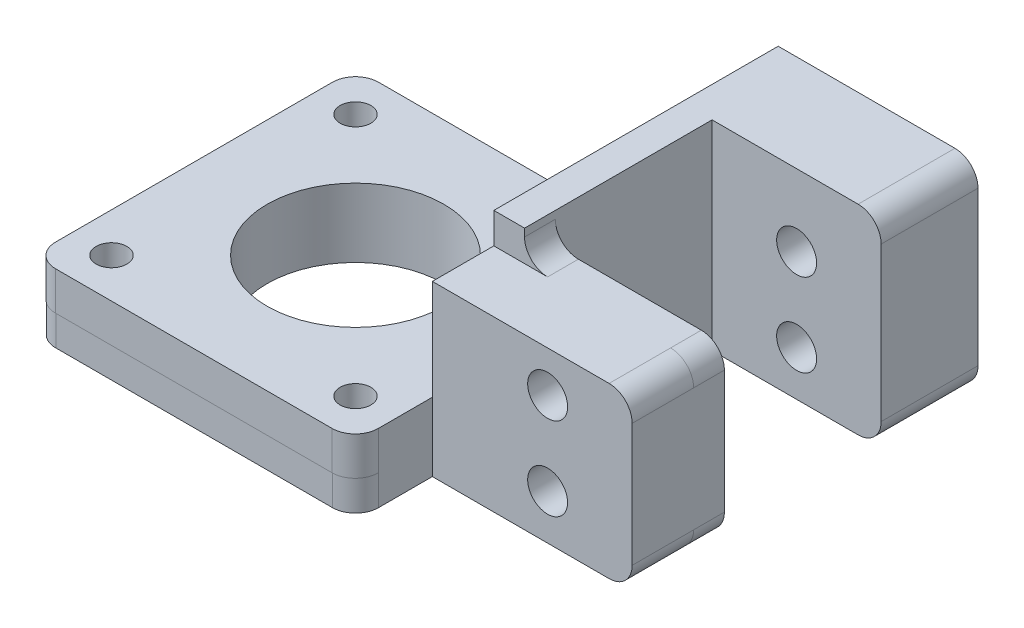
from build123d import *

# Parameters (mm, degrees)
SKETCH1_W            = 22
SKETCH1_H            = 22
BOSS_EXTRUDE2_DEPTH  = 4
SKETCH3_W            = 4
SKETCH3_H            = 22
BOSS_EXTRUDE3_DEPTH  = 24
SKETCH4_W            = 4
SKETCH4_H            = 24
BOSS_EXTRUDE4_DEPTH  = 4
SKETCH5_W            = 24
SKETCH5_H            = 4
BOSS_EXTRUDE5_DEPTH  = 24
SKETCH6_W            = 42
SKETCH6_H            = 3.943894778
BOSS_EXTRUDE6_DEPTH  = 42
SKETCH8_W            = 42
SKETCH8_H            = 42
BOSS_EXTRUDE7_DEPTH  = 4
SKETCH9_R            = 11.5
CUT_EXTRUDE1_DEPTH   = 4
SKETCH10_R           = 2.6
CUT_EXTRUDE2_DEPTH   = 4
SKETCH11_R           = 2.6
CUT_EXTRUDE3_DEPTH   = 4
FILLET1_R            = 3
SKETCH12_W           = 11.614383954
SKETCH12_H           = 9.896110461
BOSS_EXTRUDE8_DEPTH  = 4
SKETCH13_R           = 2.6
CUT_EXTRUDE5_DEPTH   = 4
SKETCH15_R           = 2
CUT_EXTRUDE7_DEPTH   = 27
SKETCH16_W           = 42
SKETCH16_H           = 42
CUT_EXTRUDE8_DEPTH   = 10
SKETCH17_W           = 42
SKETCH17_H           = 42.03828493
BOSS_EXTRUDE9_DEPTH  = 5
FILLET2_R            = 3
FILLET3_R            = 3
SKETCH18_R           = 2
SKETCH18_R_2         = 11.5
CUT_EXTRUDE9_DEPTH   = 5
SKETCH19_W           = 26
SKETCH19_H           = 22
BOSS_EXTRUDE11_DEPTH = 8
FILLET4_R            = 3
FILLET5_R            = 3
SKETCH20_W           = 4
SKETCH20_H           = 20
BOSS_EXTRUDE12_DEPTH = 26
SKETCH21_W           = 4
SKETCH21_H           = 26
BOSS_EXTRUDE13_DEPTH = 13
SKETCH25_W           = 12.6
SKETCH25_H           = 26
BOSS_EXTRUDE15_DEPTH = 22
FILLET8_R            = 3
FILLET9_R            = 3
SKETCH27_R           = 2.6
CUT_EXTRUDE10_DEPTH  = 22
SKETCH28_R           = 2.6
CUT_EXTRUDE11_DEPTH  = 46.0000001


with BuildPart() as part:
    # Sketch1 → Boss-Extrude2 (new body)
    with BuildSketch(Plane.XY):
        Rectangle(SKETCH1_W, SKETCH1_H)
    extrude(amount=BOSS_EXTRUDE2_DEPTH)

    # Sketch3 → Boss-Extrude3 (add)
    with BuildSketch(Plane.XY.offset(4)):
        with Locations((-13, 0)):
            Rectangle(SKETCH3_W, SKETCH3_H)
    extrude(amount=-BOSS_EXTRUDE3_DEPTH)

    # Sketch4 → Boss-Extrude4 (add)
    with BuildSketch(Plane(origin=(0, 11, 0), x_dir=(1, 0, 0), z_dir=(0, 1, 0))):
        with Locations((-13, 8)):
            Rectangle(SKETCH4_W, SKETCH4_H)
    extrude(amount=BOSS_EXTRUDE4_DEPTH)

    # Sketch5 → Boss-Extrude5 (add)
    with BuildSketch(Plane(origin=(-11, 0, 0), x_dir=(0, 0, -1), z_dir=(1, 0, 0))):
        with Locations((8, 13)):
            Rectangle(SKETCH5_W, SKETCH5_H)
    extrude(amount=-BOSS_EXTRUDE5_DEPTH)

    # Sketch6 → Boss-Extrude6 (add)
    with BuildSketch(Plane.ZY.offset(15)):
        with Locations((1, -9.028052611)):
            Rectangle(SKETCH6_W, SKETCH6_H)
    extrude(amount=BOSS_EXTRUDE6_DEPTH)

    # Sketch8 → Boss-Extrude7 (add)
    with BuildSketch(Plane(origin=(0, 15, 0), x_dir=(1, 0, 0), z_dir=(0, 1, 0))):
        with Locations((-36, -1)):
            Rectangle(SKETCH8_W, SKETCH8_H)
    extrude(amount=-BOSS_EXTRUDE7_DEPTH)

    # Sketch9 → Cut-Extrude1 (cut)
    with BuildSketch(Plane.XZ.offset(11)):
        with Locations((-36, 1)):
            Circle(SKETCH9_R)
    extrude(amount=-CUT_EXTRUDE1_DEPTH, mode=Mode.SUBTRACT)

    # Sketch10 → Cut-Extrude2 (cut)
    with BuildSketch(Plane(origin=(0, 15, 0), x_dir=(1, 0, 0), z_dir=(0, 1, 0))):
        with Locations((-34, -1)):
            Circle(SKETCH10_R)
    extrude(amount=-CUT_EXTRUDE2_DEPTH, mode=Mode.SUBTRACT)

    # Sketch11 → Cut-Extrude3 (cut)
    with BuildSketch(Plane.XY.offset(4)):
        with Locations((0, 5.660439733)):
            Circle(SKETCH11_R)
        with Locations((0, -5.136008772)):
            Circle(SKETCH11_R)
    extrude(amount=-CUT_EXTRUDE3_DEPTH, mode=Mode.SUBTRACT)

    # Fillet1
    fillet1_edges = [part.edges().sort_by_distance(p)[0] for p in [
        (-11, 2, -20),
        (-11, 11, 2),
        (-15, -9.028052611, 22),
        (-57, -9.028052611, -20),
        (-57, -9.028052611, 22),
        (11, -11, 2),
        (11, 11, 2),
        (-57, 13, 22),
        (-57, 13, -20),
        (-15, 13, 22),
    ]]
    fillet(fillet1_edges, radius=FILLET1_R)

    # Sketch12 → Boss-Extrude8 (add)
    with BuildSketch(Plane(origin=(0, 15, 0), x_dir=(1, 0, 0), z_dir=(0, 1, 0))):
        with Locations((-34.256477643, -1.105652727)):
            Rectangle(SKETCH12_W, SKETCH12_H)
    extrude(amount=-BOSS_EXTRUDE8_DEPTH)

    # Sketch13 → Cut-Extrude5 (cut)
    with BuildSketch(Plane.XZ.offset(-11)):
        with Locations((-36, 1)):
            Circle(SKETCH13_R)
    extrude(amount=-CUT_EXTRUDE5_DEPTH, mode=Mode.SUBTRACT)

    # Sketch15 → Cut-Extrude7 (cut, through all)
    with BuildSketch(Plane.XZ.offset(11)):
        with Locations((-20.125452762, 16.874547238)):
            Circle(SKETCH15_R)
        with Locations((-51.874547238, 16.874547238)):
            Circle(SKETCH15_R)
        with Locations((-51.874547238, -14.874547238)):
            Circle(SKETCH15_R)
        with Locations((-20.125452762, -14.874547238)):
            Circle(SKETCH15_R)
    extrude(amount=-CUT_EXTRUDE7_DEPTH, mode=Mode.SUBTRACT)

    # Sketch16 → Cut-Extrude8 (cut)
    with BuildSketch(Plane.XZ.offset(-11)):
        with Locations((-36, 1)):
            Rectangle(SKETCH16_W, SKETCH16_H)
    extrude(amount=-CUT_EXTRUDE8_DEPTH, mode=Mode.SUBTRACT)

    # Sketch17 → Boss-Extrude9 (add)
    with BuildSketch(Plane(origin=(0, -7.056105222, 0), x_dir=(1, 0, 0), z_dir=(0, 1, 0))):
        with Locations((-36, -1.019142465)):
            Rectangle(SKETCH17_W, SKETCH17_H)
    extrude(amount=BOSS_EXTRUDE9_DEPTH)

    # Fillet2
    fillet2_edges = [part.edges().sort_by_distance(p)[0] for p in [
        (-15, -4.556105222, 22.03828493),
    ]]
    fillet(fillet2_edges, radius=FILLET2_R)

    # Fillet3
    fillet3_edges = [part.edges().sort_by_distance(p)[0] for p in [
        (-57, -4.556105222, -20),
        (-57, -4.556105222, 22.03828493),
    ]]
    fillet(fillet3_edges, radius=FILLET3_R)

    # Sketch18 → Cut-Extrude9 (cut)
    with BuildSketch(Plane.XZ.offset(7.056105222)):
        with Locations((-20.125452762, 16.874547238)):
            Circle(SKETCH18_R)
        with Locations((-51.874547238, 16.874547238)):
            Circle(SKETCH18_R)
        with Locations((-51.874547238, -14.874547238)):
            Circle(SKETCH18_R)
        with Locations((-20.125452762, -14.874547238)):
            Circle(SKETCH18_R)
        with Locations((-36, 1)):
            Circle(SKETCH18_R_2)
    extrude(amount=-CUT_EXTRUDE9_DEPTH, mode=Mode.SUBTRACT)

    # Sketch19 → Boss-Extrude11 (add)
    with BuildSketch(Plane.XY.offset(4)):
        with Locations((-2, 0)):
            Rectangle(SKETCH19_W, SKETCH19_H)
    extrude(amount=BOSS_EXTRUDE11_DEPTH)

    # Fillet4
    fillet4_edges = [part.edges().sort_by_distance(p)[0] for p in [
        (11, 11, 8),
    ]]
    fillet(fillet4_edges, radius=FILLET4_R)

    # Fillet5
    fillet5_edges = [part.edges().sort_by_distance(p)[0] for p in [
        (11, -11, 8),
    ]]
    fillet(fillet5_edges, radius=FILLET5_R)

    # Sketch20 → Boss-Extrude12 (add, through all)
    with BuildSketch(Plane(origin=(0, 15, 0), x_dir=(1, 0, 0), z_dir=(0, 1, 0))):
        with Locations((-13, 10)):
            Rectangle(SKETCH20_W, SKETCH20_H)
    extrude(amount=-BOSS_EXTRUDE12_DEPTH)

    # Sketch21 → Boss-Extrude13 (add)
    with BuildSketch(Plane(origin=(0, 0, -20), x_dir=(-1, 0, 0), z_dir=(0, 0, -1))):
        with Locations((13, 2)):
            Rectangle(SKETCH21_W, SKETCH21_H)
    extrude(amount=BOSS_EXTRUDE13_DEPTH)

    # Sketch25 → Boss-Extrude15 (add)
    with BuildSketch(Plane(origin=(-11, 0, 0), x_dir=(0, 0, -1), z_dir=(1, 0, 0))):
        with Locations((26.7, 2)):
            Rectangle(SKETCH25_W, SKETCH25_H)
    extrude(amount=BOSS_EXTRUDE15_DEPTH)

    # Fillet8
    fillet8_edges = [part.edges().sort_by_distance(p)[0] for p in [
        (11, 15, -26.7),
    ]]
    fillet(fillet8_edges, radius=FILLET8_R)

    # Fillet9
    fillet9_edges = [part.edges().sort_by_distance(p)[0] for p in [
        (11, -11, -26.7),
    ]]
    fillet(fillet9_edges, radius=FILLET9_R)

    # Sketch27 → Cut-Extrude10 (cut)
    with BuildSketch(Plane(origin=(0, 0, 0), x_dir=(-1, 0, 0), z_dir=(0, 0, -1))):
        with Locations((0, 5.660439733)):
            Circle(SKETCH27_R)
        with Locations((0, -5.136008772)):
            Circle(SKETCH27_R)
    extrude(amount=-CUT_EXTRUDE10_DEPTH, mode=Mode.SUBTRACT)

    # Sketch28 → Cut-Extrude11 (cut, through all)
    with BuildSketch(Plane.XY.offset(12)):
        with Locations((0, 5.660439733)):
            Circle(SKETCH28_R)
        with Locations((0, -5.136008772)):
            Circle(SKETCH28_R)
    extrude(amount=-CUT_EXTRUDE11_DEPTH, mode=Mode.SUBTRACT)


solid = part.part
